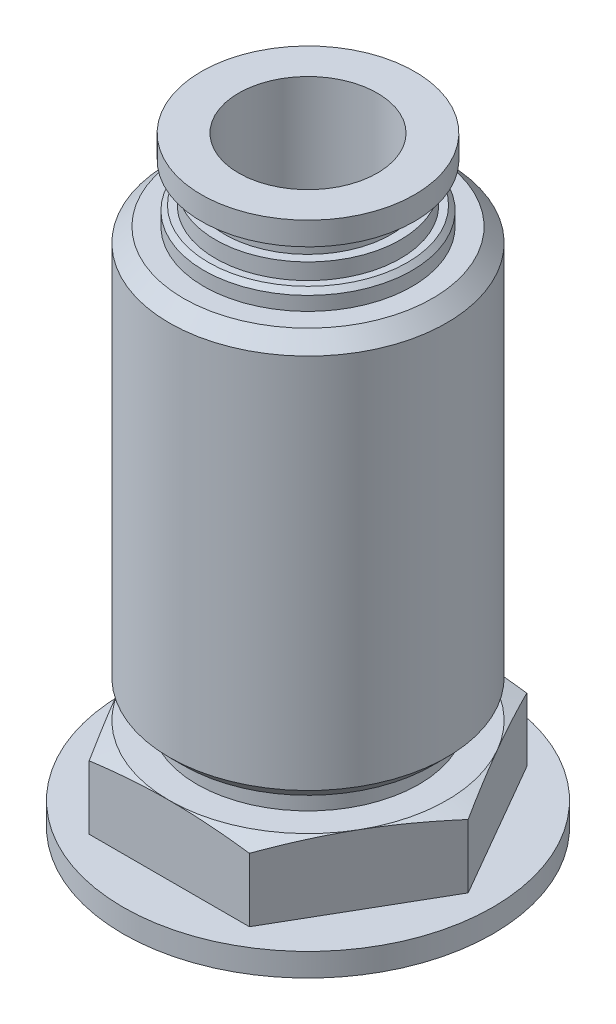
from build123d import *

# Parameters (mm, degrees)
SKETCH5_W          = 34
SKETCH5_H          = 34
CUT_EXTRUDE1_DEPTH = 3
SKETCH6_W          = 3
SKETCH6_H          = 11.7
SKETCH7_W          = 4.8
SKETCH7_H          = 1


with BuildPart() as part:
    # Sketch1 → Revolve1 (revolve)
    with BuildSketch(Plane.XY):
        Polygon((0, 34), (4.615384615, 34), (4.615384615, 33), (3.6, 33), (3.6, 32), (4, 32), (4, 12), (4.8, 12), (4.8, 9.5), (3.157894737, 9.5), (3.157894737, 8), (0, 8), align=None)
    revolve(axis=Axis((0, 8, 0), (0, 1, 0)))

    # Sketch2 → Revolve2 (revolve)
    with BuildSketch(Plane.XY):
        Polygon((0, 30.5), (5.3865, 30.5), (6, 29.8865), (6, 13.6135), (5.3865, 13), (0, 13), align=None)
    revolve(axis=Axis((0, 13, 0), (0, 1, 0)))

    # Sketch3 → Revolve3 (revolve)
    with BuildSketch(Plane.XY):
        Polygon((0, 32), (3.5, 32), (4, 31.3), (4.3, 31.3), (4.5, 31.1), (4.5, 30.5), (0, 30.5), align=None)
    revolve(axis=Axis((0, 30.5, 0), (0, 1, 0)))

    # Sketch4 → Revolve4 (revolve)
    with BuildSketch(Plane.XY):
        Polygon((0, 12), (6, 12), (7.2, 11.678460969), (7.2, 9), (8, 9), (8, 8), (0, 8), align=None)
    revolve(axis=Axis((0, 8, 0), (0, 1, 0)))

    # Sketch5 → Cut-Extrude1 (cut)
    with BuildSketch(Plane(origin=(0, 12, 0), x_dir=(-1, 0, 0), z_dir=(0, 1, 0))):
        Rectangle(SKETCH5_W, SKETCH5_H)
        Polygon((6.92820323, 0), (3.464101615, 6), (-3.464101615, 6), (-6.92820323, 0), (-3.464101615, -6), (3.464101615, -6), align=None, mode=Mode.SUBTRACT)
    extrude(amount=-CUT_EXTRUDE1_DEPTH, mode=Mode.SUBTRACT)

    # Sketch6 → Cut-Revolve1 (revolve, cut)
    with BuildSketch(Plane.XY):
        with Locations((1.5, 28.15)):
            Rectangle(SKETCH6_W, SKETCH6_H)
    revolve(axis=Axis((0, 22.3, 0), (0, 1, 0)), mode=Mode.SUBTRACT)

    # Sketch7 → Revolve5 (revolve)
    with BuildSketch(Plane.XY):
        with Locations((2.4, 12.5)):
            Rectangle(SKETCH7_W, SKETCH7_H)
    revolve(axis=Axis((0, 12, 0), (0, 1, 0)))


solid = part.part
